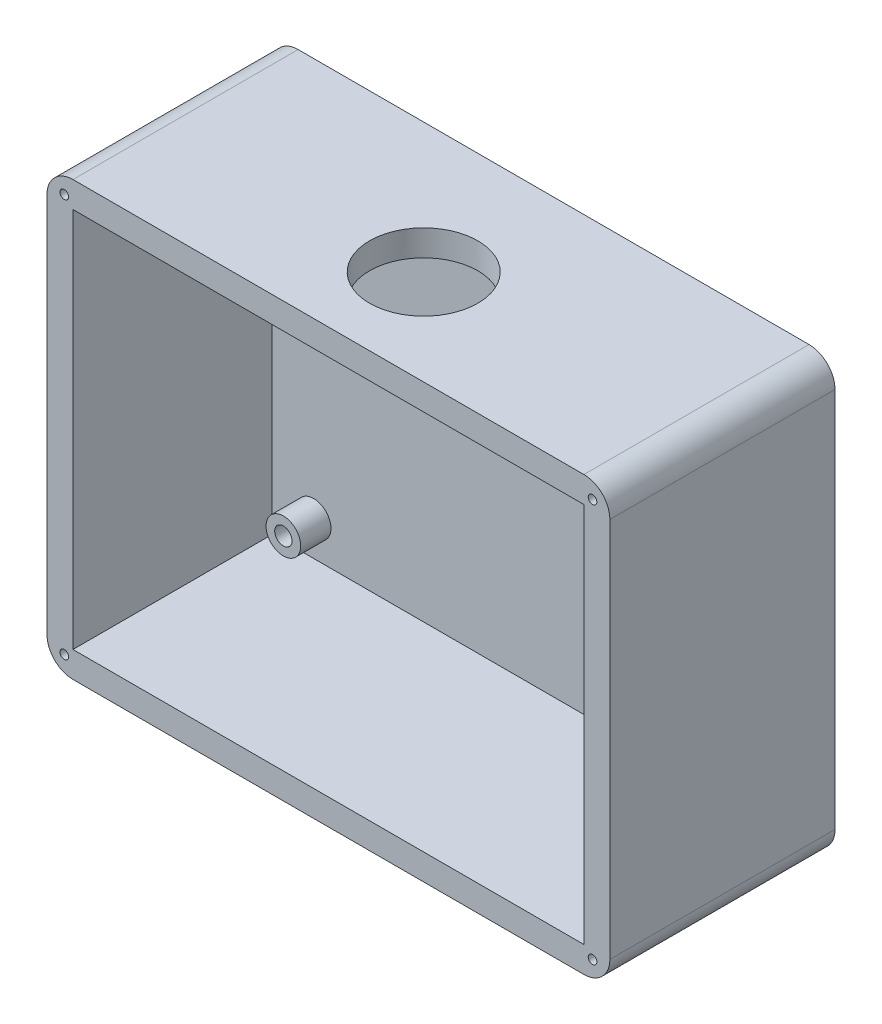
from build123d import *

# Parameters (mm, degrees)
SKIZZE1_W                          = 65
SKIZZE1_H                          = 50
AUFSATZ_LINEAR_AUSTRAGEN1_DEPTH    = 3
SKIZZE2_W                          = 65
SKIZZE2_H                          = 50
SKIZZE2_W_2                        = 59
SKIZZE2_H_2                        = 44
AUFSATZ_LINEAR_AUSTRAGEN2_DEPTH    = 23
SKIZZE4_R                          = 2
SKIZZE4_R_2                        = 1
AUFSATZ_LINEAR_AUSTRAGEN3_DEPTH    = 3.5
SCHNITT_LINEAR_AUSTRAGEN1_REACH    = 52
SKIZZE5_R                          = 6.25
VERRUNDUNG1_R                      = 3
F_1_0_1_DURCHMESSER_BOHRUNG1_D     = 1
F_1_0_1_DURCHMESSER_BOHRUNG1_DEPTH = 15
F_1_0_1_DURCHMESSER_BOHRUNG1_TIP   = 0.30043031


with BuildPart() as part:
    # Skizze1 → Aufsatz-Linear austragen1 (new body)
    with BuildSketch(Plane.XY):
        with Locations((32.5, -25)):
            Rectangle(SKIZZE1_W, SKIZZE1_H)
    extrude(amount=AUFSATZ_LINEAR_AUSTRAGEN1_DEPTH)

    # Skizze2 → Aufsatz-Linear austragen2 (add)
    with BuildSketch(Plane.XY.offset(3)):
        with Locations((32.5, -25)):
            Rectangle(SKIZZE2_W, SKIZZE2_H)
        with Locations((32.5, -25)):
            Rectangle(SKIZZE2_W_2, SKIZZE2_H_2, mode=Mode.SUBTRACT)
    extrude(amount=AUFSATZ_LINEAR_AUSTRAGEN2_DEPTH)

    # Skizze4 → Aufsatz-Linear austragen3 (add)
    with BuildSketch(Plane.XY.offset(3)):
        with Locations((7.797786215, -7)):
            Circle(SKIZZE4_R)
        with Locations((7.797786215, -7)):
            Circle(SKIZZE4_R_2, mode=Mode.SUBTRACT)
        with Locations((56.797786215, -7)):
            Circle(SKIZZE4_R)
        with Locations((56.797786215, -7)):
            Circle(SKIZZE4_R_2, mode=Mode.SUBTRACT)
        with Locations((56.797786215, -43)):
            Circle(SKIZZE4_R)
        with Locations((56.797786215, -43)):
            Circle(SKIZZE4_R_2, mode=Mode.SUBTRACT)
        with Locations((7.797786215, -43)):
            Circle(SKIZZE4_R)
        with Locations((7.797786215, -43)):
            Circle(SKIZZE4_R_2, mode=Mode.SUBTRACT)
    extrude(amount=AUFSATZ_LINEAR_AUSTRAGEN3_DEPTH)

    # Skizze5 → Schnitt-Linear austragen1 (cut, up to next)
    with BuildSketch(Plane(origin=(0, 0, 0), x_dir=(1, 0, 0), z_dir=(0, 1, 0)), mode=Mode.PRIVATE) as schnitt_linear_austragen1_sk1:
        with Locations((32.5, -15)):
            Circle(SKIZZE5_R)
    schnitt_linear_austragen1_tool1 = extrude(schnitt_linear_austragen1_sk1.sketch, amount=-SCHNITT_LINEAR_AUSTRAGEN1_REACH, mode=Mode.PRIVATE) & part.part
    add(schnitt_linear_austragen1_tool1.solids().sort_by_distance((32.5, 0, 15))[0], mode=Mode.SUBTRACT)

    # Verrundung1
    verrundung1_edges = [part.edges().sort_by_distance(p)[0] for p in [
        (0, 0, 13),
        (65, 0, 13),
        (65, -50, 13),
        (0, -50, 13),
    ]]
    fillet(verrundung1_edges, radius=VERRUNDUNG1_R)

    # Ø1.0 (1) Durchmesser Bohrung1
    with Locations(Plane.XY.offset(26)):
        with Locations((63, -48), (63, -2), (2, -2), (2, -48)):
            Hole(F_1_0_1_DURCHMESSER_BOHRUNG1_D / 2, depth=F_1_0_1_DURCHMESSER_BOHRUNG1_DEPTH)
            with Locations((0, 0, -(F_1_0_1_DURCHMESSER_BOHRUNG1_DEPTH + F_1_0_1_DURCHMESSER_BOHRUNG1_TIP / 2))):  # 118° drill point
                Cone(0, F_1_0_1_DURCHMESSER_BOHRUNG1_D / 2, F_1_0_1_DURCHMESSER_BOHRUNG1_TIP, mode=Mode.SUBTRACT)


solid = part.part
